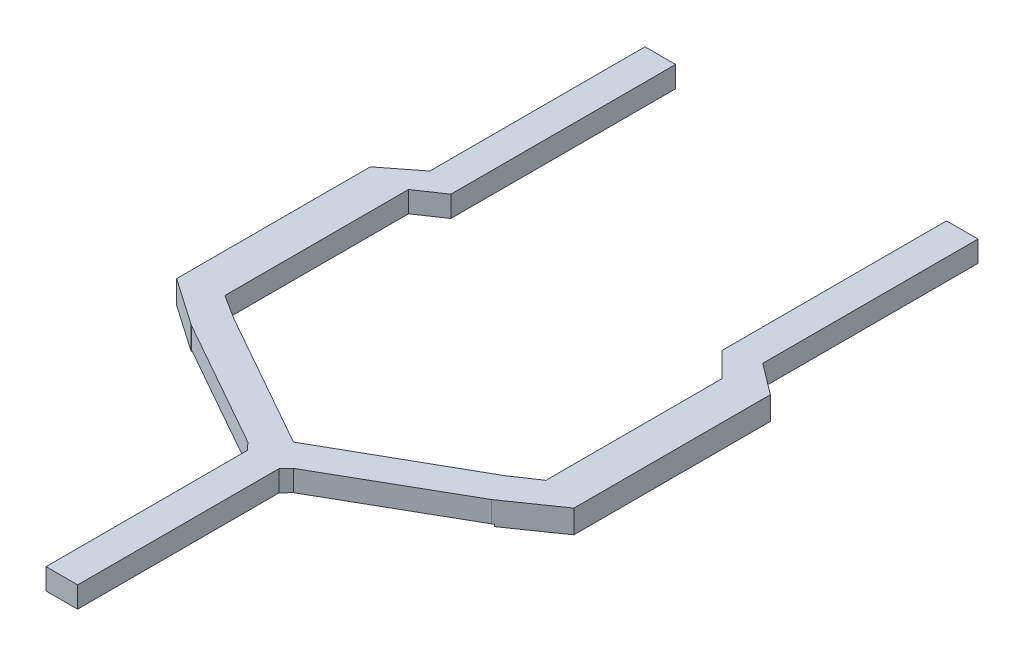
from build123d import *

# Parameters (mm, degrees)
BOSS_EXTRUDE1_DEPTH = 2.54
BOSS_EXTRUDE3_DEPTH = 2.794
BOSS_EXTRUDE4_DEPTH = 2.794
CUT_EXTRUDE1_DEPTH  = 2.794
CUT_EXTRUDE2_DEPTH  = 2.794
CUT_EXTRUDE3_DEPTH  = 2.794
CUT_EXTRUDE4_DEPTH  = 2.794


with BuildPart() as part:
    # Sketch2 → Boss-Extrude1 (new body)
    with BuildSketch(Plane(origin=(0, 0, 0), x_dir=(1, 0, 0), z_dir=(0, 1, 0))):
        Polygon((-1.905, 0), (1.905, 0), (1.905, 24.289959425), (2.748388443, 25.169443727), (18.139363721, 33.964286743), (20.066, 37.152417336), (20.066, 90.357876746), (16.27045958, 90.357876746), (16.27045958, 37.152417336), (0, 27.917832169), (-16.380395118, 37.152417336), (-16.380395118, 90.357876746), (-20.066, 90.357876746), (-20.066, 37.152417336), (-18.359234796, 33.964286743), (-2.748388443, 25.169443727), (-1.905, 24.289959425), align=None)
    extrude(amount=BOSS_EXTRUDE1_DEPTH)

    # Sketch3 → Boss-Extrude3 (add)
    with BuildSketch(Plane(origin=(0, 2.54, 0), x_dir=(1, 0, 0), z_dir=(0, 1, 0))):
        Polygon((-20.066, 64.416430686), (-23.843651965, 64.416430686), (-24.093769894, 64.416430686), (-24.093769894, 34.012983608), (-18.385304655, 34.012983608), (-20.066, 37.152417336), align=None)
    extrude(amount=-BOSS_EXTRUDE3_DEPTH)

    # Sketch5 → Boss-Extrude4 (add)
    with BuildSketch(Plane(origin=(0, 2.54, 0), x_dir=(1, 0, 0), z_dir=(0, 1, 0))):
        Polygon((23.79791373, 64.416430686), (20.066, 64.416430686), (20.066, 37.152417336), (18.139363721, 33.964286743), (17.94697653, 33.854351205), (23.79791373, 33.854351205), align=None)
    extrude(amount=-BOSS_EXTRUDE4_DEPTH)

    # Sketch6 → Cut-Extrude1 (cut)
    with BuildSketch(Plane(origin=(0, 2.54, 0), x_dir=(1, 0, 0), z_dir=(0, 1, 0))):
        Polygon((-16.380395118, 37.152417336), (-19.425262821, 39.079248043), (-19.425262821, 61.216281017), (-16.380395118, 63.274089716), align=None)
    extrude(amount=-CUT_EXTRUDE1_DEPTH, mode=Mode.SUBTRACT)

    # Sketch7 → Cut-Extrude2 (cut)
    with BuildSketch(Plane(origin=(0, 2.54, 0), x_dir=(1, 0, 0), z_dir=(0, 1, 0))):
        Polygon((16.27045958, 37.152417336), (19.210779399, 39.131257015), (19.210779399, 60.348815791), (16.022648806, 63.536946385), align=None)
    extrude(amount=-CUT_EXTRUDE2_DEPTH, mode=Mode.SUBTRACT)

    # Sketch8 → Cut-Extrude3 (cut)
    with BuildSketch(Plane(origin=(0, 2.54, 0), x_dir=(1, 0, 0), z_dir=(0, 1, 0))):
        Polygon((-18.359234796, 33.964286743), (-25.982779442, 39.241192553), (-25.982779442, 59.799138103), (-20.066, 64.416430686), (-26.704115548, 65.235310973), (-32.139169553, 50.784424011), (-24.093769894, 30.886091687), align=None)
    extrude(amount=-CUT_EXTRUDE3_DEPTH, mode=Mode.SUBTRACT)

    # Sketch9 → Cut-Extrude4 (cut)
    with BuildSketch(Plane(origin=(0, 2.54, 0), x_dir=(1, 0, 0), z_dir=(0, 1, 0))):
        Polygon((17.94697653, 33.854351205), (23.79791373, 37.9219661), (26.535723591, 53.149224599), (25.166818661, 60.568686867), (20.066, 64.416430686), (22.61640933, 67.797418641), (32.063184465, 64.416430686), (29.094924947, 33.854351205), (20.441248246, 27.838251042), align=None)
    extrude(amount=-CUT_EXTRUDE4_DEPTH, mode=Mode.SUBTRACT)


solid = part.part
